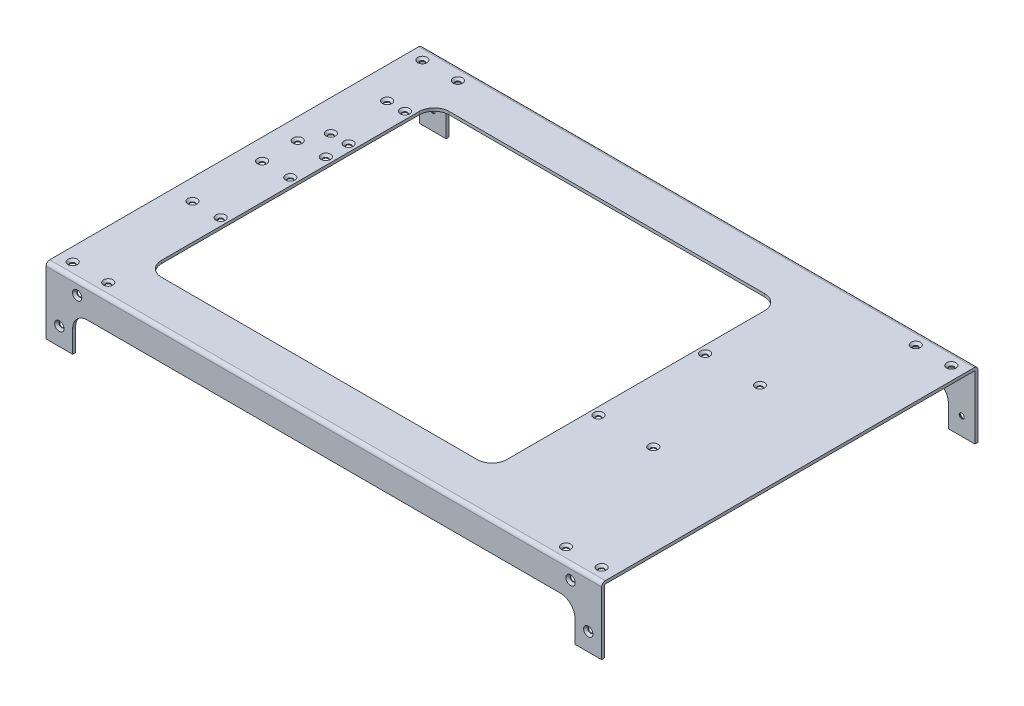
from build123d import *

# Parameters (mm, degrees)
BOSS_EXTRUDE1_DEPTH                             = 187.5
CUT_EXTRUDE1_DEPTH                              = 255
CUT_EXTRUDE2_DEPTH                              = 10
SKETCH4_R                                       = 1.5
CUT_EXTRUDE3_DEPTH                              = 255
SKETCH5_R                                       = 1.5
CUT_EXTRUDE4_DEPTH                              = 10
CSK_FOR_M3_FLAT_HEAD_MACHINE_SCREW1_D           = 3.4
CSK_FOR_M3_FLAT_HEAD_MACHINE_SCREW1_CSINK_D     = 6.3
CSK_FOR_M3_FLAT_HEAD_MACHINE_SCREW1_CSINK_ANGLE = 90
CSK_FOR_M3_FLAT_HEAD_MACHINE_SCREW2_D           = 3.4
CSK_FOR_M3_FLAT_HEAD_MACHINE_SCREW2_DEPTH       = 10
CSK_FOR_M3_FLAT_HEAD_MACHINE_SCREW2_CSINK_D     = 6.3
CSK_FOR_M3_FLAT_HEAD_MACHINE_SCREW2_CSINK_ANGLE = 90
CSK_FOR_M3_FLAT_HEAD_MACHINE_SCREW2_TIP         = 1.021463052
CSK_FOR_M3_FLAT_HEAD_MACHINE_SCREW3_D           = 3.4
CSK_FOR_M3_FLAT_HEAD_MACHINE_SCREW3_DEPTH       = 10
CSK_FOR_M3_FLAT_HEAD_MACHINE_SCREW3_CSINK_D     = 6.3
CSK_FOR_M3_FLAT_HEAD_MACHINE_SCREW3_CSINK_ANGLE = 90
CSK_FOR_M3_FLAT_HEAD_MACHINE_SCREW3_TIP         = 1.021463052


with BuildPart() as part:
    # Sketch1 → Boss-Extrude1 (new body, symmetric)
    with BuildSketch(Plane(origin=(0, 0, 0), x_dir=(0, 0, -1), z_dir=(1, 0, 0))):
        with BuildLine():
            Line((125, -45), (127, -45))
            Line((127, -45), (127, -2.5))
            ThreePointArc((127, -2.5), (126.267766953, -0.732233047), (124.5, 0))
            Line((124.5, 0), (-124.5, 0))
            ThreePointArc((-124.5, 0), (-126.267766953, -0.732233047), (-127, -2.5))
            Line((-127, -2.5), (-127, -45))
            Line((-127, -45), (-125, -45))
            Line((-125, -45), (-125, -2.5))
            ThreePointArc((-125, -2.5), (-124.853553391, -2.146446609), (-124.5, -2))
            Line((-124.5, -2), (124.5, -2))
            ThreePointArc((124.5, -2), (124.853553391, -2.146446609), (125, -2.5))
            Line((125, -2.5), (125, -45))
        make_face()
    extrude(amount=BOSS_EXTRUDE1_DEPTH, both=True)

    # Sketch2 → Cut-Extrude1 (cut, through all)
    with BuildSketch(Plane.XY.offset(127)):
        with BuildLine():
            Line((-169.5, -45), (169.5, -45))
            Line((169.5, -45), (169.5, -30))
            ThreePointArc((169.5, -30), (166.571067812, -22.928932188), (159.5, -20))
            Line((159.5, -20), (-159.5, -20))
            ThreePointArc((-159.5, -20), (-166.571067812, -22.928932188), (-169.5, -30))
            Line((-169.5, -30), (-169.5, -45))
        make_face()
    extrude(amount=-CUT_EXTRUDE1_DEPTH, mode=Mode.SUBTRACT)

    # Sketch3 → Cut-Extrude2 (cut)
    with BuildSketch(Plane(origin=(0, 0, 0), x_dir=(1, 0, 0), z_dir=(0, 1, 0))):
        with BuildLine():
            Line((-139.5, 97), (73.5, 97))
            ThreePointArc((73.5, 97), (80.571067812, 94.071067812), (83.5, 87))
            Line((83.5, 87), (83.5, -87))
            ThreePointArc((83.5, -87), (80.571067812, -94.071067812), (73.5, -97))
            Line((73.5, -97), (-139.5, -97))
            ThreePointArc((-139.5, -97), (-146.571067812, -94.071067812), (-149.5, -87))
            Line((-149.5, -87), (-149.5, 87))
            ThreePointArc((-149.5, 87), (-146.571067812, 94.071067812), (-139.5, 97))
        make_face()
    extrude(amount=-CUT_EXTRUDE2_DEPTH, mode=Mode.SUBTRACT)

    # Sketch4 → Cut-Extrude3 (cut, through all)
    with BuildSketch(Plane.XY.offset(127)):
        with Locations((-178.5, -33)):
            Circle(SKETCH4_R)
        with Locations((-166.5, -9)):
            Circle(SKETCH4_R)
        with Locations((166.5, -9)):
            Circle(SKETCH4_R)
        with Locations((178.5, -33)):
            Circle(SKETCH4_R)
    extrude(amount=-CUT_EXTRUDE3_DEPTH, mode=Mode.SUBTRACT)

    # Sketch5 → Cut-Extrude4 (cut)
    with BuildSketch(Plane(origin=(0, 0, 0), x_dir=(1, 0, 0), z_dir=(0, 1, 0))):
        with Locations(Location((-178.5, 118, 0), (0, 0, 270))):  # turned: the seam where the file's is
            Circle(SKETCH5_R)
        with Locations(Location((-154.5, 118, 0), (0, 0, 270))):  # turned: the seam where the file's is
            Circle(SKETCH5_R)
        with Locations(Location((154.5, 118, 0), (0, 0, 270))):  # turned: the seam where the file's is
            Circle(SKETCH5_R)
        with Locations(Location((178.5, 118, 0), (0, 0, 270))):  # turned: the seam where the file's is
            Circle(SKETCH5_R)
        with Locations(Location((178.5, -118, 0), (0, 0, 270))):  # turned: the seam where the file's is
            Circle(SKETCH5_R)
        with Locations(Location((154.5, -118, 0), (0, 0, 270))):  # turned: the seam where the file's is
            Circle(SKETCH5_R)
        with Locations(Location((-178.5, -118, 0), (0, 0, 270))):  # turned: the seam where the file's is
            Circle(SKETCH5_R)
        with Locations(Location((-154.5, -118, 0), (0, 0, 270))):  # turned: the seam where the file's is
            Circle(SKETCH5_R)
        with Locations(Location((88.5, 41.85, 0), (0, 0, 270))):  # turned: the seam where the file's is
            Circle(SKETCH5_R)
        with Locations(Location((88.5, -30.15, 0), (0, 0, 270))):  # turned: the seam where the file's is
            Circle(SKETCH5_R)
        with Locations(Location((125.5, 41.85, 0), (0, 0, 270))):  # turned: the seam where the file's is
            Circle(SKETCH5_R)
        with Locations(Location((125.5, -30.15, 0), (0, 0, 270))):  # turned: the seam where the file's is
            Circle(SKETCH5_R)
        with Locations(Location((-154.5, 28.85, 0), (0, 0, 270))):  # turned: the seam where the file's is
            Circle(SKETCH5_R)
        with Locations(Location((-173.5, 28.85, 0), (0, 0, 270))):  # turned: the seam where the file's is
            Circle(SKETCH5_R)
        with Locations(Location((-173.5, 4.85, 0), (0, 0, 270))):  # turned: the seam where the file's is
            Circle(SKETCH5_R)
        with Locations(Location((-154.5, 4.85, 0), (0, 0, 270))):  # turned: the seam where the file's is
            Circle(SKETCH5_R)
        with Locations(Location((-154.5, -42.15, 0), (0, 0, 270))):  # turned: the seam where the file's is
            Circle(SKETCH5_R)
        with Locations(Location((-173.5, -42.15, 0), (0, 0, 270))):  # turned: the seam where the file's is
            Circle(SKETCH5_R)
        with Locations(Location((-166.5, 82.25, 0), (0, 0, 270))):  # turned: the seam where the file's is
            Circle(SKETCH5_R)
        with Locations(Location((-154.5, 82.25, 0), (0, 0, 270))):  # turned: the seam where the file's is
            Circle(SKETCH5_R)
        with Locations(Location((-166.5, 44.25, 0), (0, 0, 270))):  # turned: the seam where the file's is
            Circle(SKETCH5_R)
        with Locations(Location((-154.5, 44.25, 0), (0, 0, 270))):  # turned: the seam where the file's is
            Circle(SKETCH5_R)
    extrude(amount=-CUT_EXTRUDE4_DEPTH, mode=Mode.SUBTRACT)

    # CSK for M3 Flat Head Machine Screw1 (through all)
    with Locations(Plane(origin=(0, 0, 0), x_dir=(-1, 0, 0), z_dir=(0, 1, 0))):
        with Locations((154.5, 118), (178.5, 118), (154.5, 42.15), (173.5, 42.15), (154.5, -4.85), (173.5, -4.85), (173.5, -28.85), (154.5, -28.85), (154.5, -44.25), (166.5, -44.25), (166.5, -82.25), (154.5, -82.25), (178.5, -118), (154.5, -118), (-154.5, -118), (-178.5, -118), (-125.5, -41.85), (-88.5, -41.85), (-125.5, 30.15), (-88.5, 30.15), (-178.5, 118), (-154.5, 118)):
            CounterSinkHole(CSK_FOR_M3_FLAT_HEAD_MACHINE_SCREW1_D / 2, CSK_FOR_M3_FLAT_HEAD_MACHINE_SCREW1_CSINK_D / 2, counter_sink_angle=CSK_FOR_M3_FLAT_HEAD_MACHINE_SCREW1_CSINK_ANGLE)

    # CSK for M3 Flat Head Machine Screw2
    with Locations(Plane.XY.offset(127)):
        with Locations((166.5, -9), (178.5, -33), (-178.5, -33), (-166.5, -9)):
            CounterSinkHole(CSK_FOR_M3_FLAT_HEAD_MACHINE_SCREW2_D / 2, CSK_FOR_M3_FLAT_HEAD_MACHINE_SCREW2_CSINK_D / 2, depth=CSK_FOR_M3_FLAT_HEAD_MACHINE_SCREW2_DEPTH, counter_sink_angle=CSK_FOR_M3_FLAT_HEAD_MACHINE_SCREW2_CSINK_ANGLE)
            with Locations((0, 0, -(CSK_FOR_M3_FLAT_HEAD_MACHINE_SCREW2_DEPTH + CSK_FOR_M3_FLAT_HEAD_MACHINE_SCREW2_TIP / 2))):  # 118° drill point
                Cone(0, CSK_FOR_M3_FLAT_HEAD_MACHINE_SCREW2_D / 2, CSK_FOR_M3_FLAT_HEAD_MACHINE_SCREW2_TIP, mode=Mode.SUBTRACT)

    # CSK for M3 Flat Head Machine Screw3
    with Locations(Plane(origin=(0, 0, -127), x_dir=(-1, 0, 0), z_dir=(0, 0, -1))):
        with Locations((-166.5, -9), (178.5, -33), (166.5, -9), (-178.5, -33)):
            CounterSinkHole(CSK_FOR_M3_FLAT_HEAD_MACHINE_SCREW3_D / 2, CSK_FOR_M3_FLAT_HEAD_MACHINE_SCREW3_CSINK_D / 2, depth=CSK_FOR_M3_FLAT_HEAD_MACHINE_SCREW3_DEPTH, counter_sink_angle=CSK_FOR_M3_FLAT_HEAD_MACHINE_SCREW3_CSINK_ANGLE)
            with Locations((0, 0, -(CSK_FOR_M3_FLAT_HEAD_MACHINE_SCREW3_DEPTH + CSK_FOR_M3_FLAT_HEAD_MACHINE_SCREW3_TIP / 2))):  # 118° drill point
                Cone(0, CSK_FOR_M3_FLAT_HEAD_MACHINE_SCREW3_D / 2, CSK_FOR_M3_FLAT_HEAD_MACHINE_SCREW3_TIP, mode=Mode.SUBTRACT)


solid = part.part
